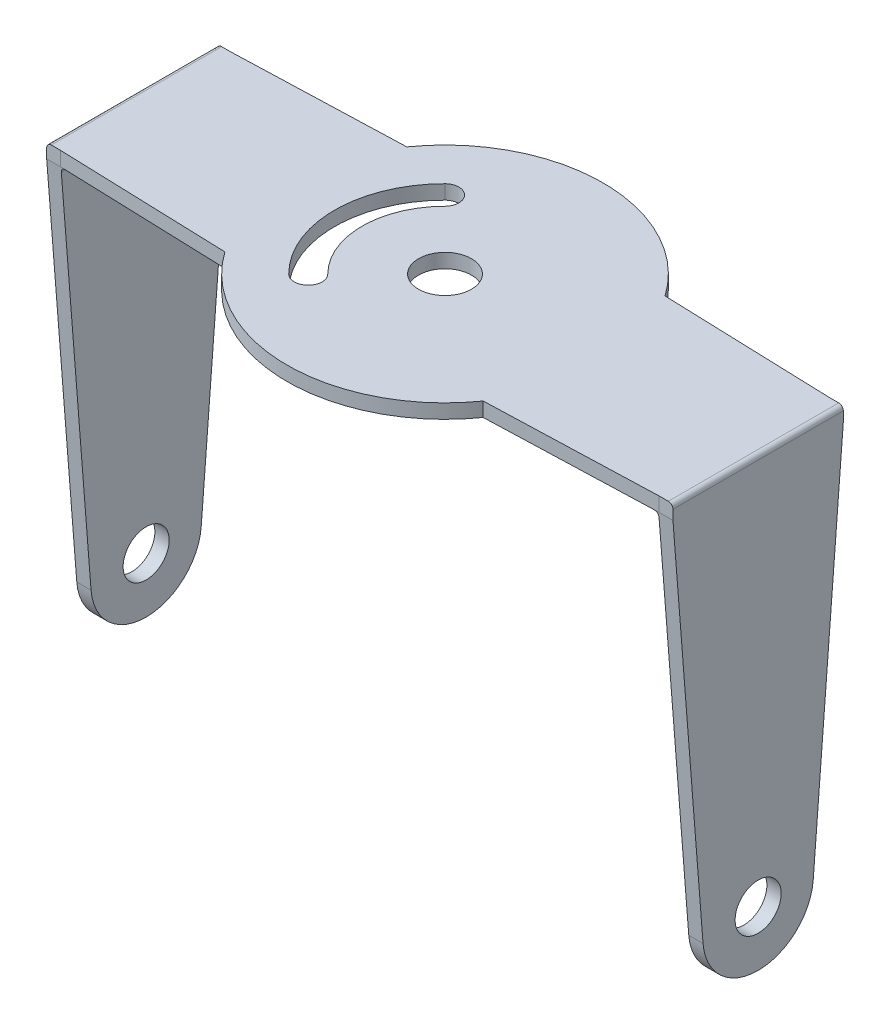
from build123d import *

# Parameters (mm, degrees)
BOSS_EXTRUDE1_DEPTH = 17.15
CUT_EXTRUDE1_DEPTH  = 69
CUT_EXTRUDE2_DEPTH  = 49.5
SKETCH4_R           = 2.875
CUT_EXTRUDE3_DEPTH  = 34.3
SKETCH5_R           = 2.5
CUT_EXTRUDE4_DEPTH  = 69
FILLET2_R           = 0.5


with BuildPart() as part:
    # Sketch1 → Boss-Extrude1 (new body, symmetric)
    with BuildSketch(Plane.XY):
        Polygon((-32.45, -6), (-32.45, 40.95), (32.45, 40.95), (32.45, -6), (34, -6), (34, 42.5), (-34, 42.5), (-34, -6), align=None)
    extrude(amount=BOSS_EXTRUDE1_DEPTH, both=True)

    # Sketch2 → Cut-Extrude1 (cut, through all)
    with BuildSketch(Plane.ZY.offset(34)):
        with BuildLine():
            Line((-5.981406604, -0.471990503), (-9.25, 40.95))
            Line((-9.25, 40.95), (-17.15, 40.95))
            Line((-17.15, 40.95), (-17.15, -6))
            Line((-17.15, -6), (0, -6))
            ThreePointArc((0, -6), (-4.07234926, -4.406355808), (-5.981406604, -0.471990503))
        make_face()
    cut_extrude1 = extrude(amount=-CUT_EXTRUDE1_DEPTH, mode=Mode.SUBTRACT)

    # Mirror1: Cut-Extrude1 across plane
    add(cut_extrude1.mirror(Plane.XY), mode=Mode.SUBTRACT)

    # Sketch3 → Cut-Extrude2 (cut, through all)
    with BuildSketch(Plane(origin=(0, 42.5, 0), x_dir=(1, 0, 0), z_dir=(0, 1, 0))):
        with BuildLine():
            Line((-32.5, -9.25), (-14.021657356, -9.875))
            ThreePointArc((-14.021657356, -9.875), (-7.898298867, -15.222988373), (0, -17.15))
            Line((0, -17.15), (-34, -17.15))
            Line((-34, -17.15), (-34, -9.25))
            Line((-34, -9.25), (-32.5, -9.25))
        make_face()
        with BuildLine():
            Line((-34, 9.25), (-34, 17.15))
            Line((-34, 17.15), (0, 17.15))
            ThreePointArc((0, 17.15), (-7.898298867, 15.222988373), (-14.021657356, 9.875))
            Line((-14.021657356, 9.875), (-32.5, 9.25))
            Line((-32.5, 9.25), (-34, 9.25))
        make_face()
    cut_extrude2 = extrude(amount=-CUT_EXTRUDE2_DEPTH, mode=Mode.SUBTRACT)

    # Mirror2: Cut-Extrude2 across plane
    add(cut_extrude2.mirror(Plane(origin=(0, 0, 0), x_dir=(0, 0, 1), z_dir=(1, 0, 0))), mode=Mode.SUBTRACT)

    # Sketch4 → Cut-Extrude3 (cut)
    with BuildSketch(Plane(origin=(0, 42.5, 0), x_dir=(1, 0, 0), z_dir=(0, 1, 0))):
        Circle(SKETCH4_R)
        with BuildLine():
            ThreePointArc((-8.485281374, 8.485281374), (-12, 0), (-8.485281374, -8.485281374))
            ThreePointArc((-8.485281374, -8.485281374), (-6.363961031, -8.485281374), (-6.363961031, -6.363961031))
            ThreePointArc((-6.363961031, -6.363961031), (-9, 0), (-6.363961031, 6.363961031))
            ThreePointArc((-6.363961031, 6.363961031), (-6.363961031, 8.485281374), (-8.485281374, 8.485281374))
        make_face()
    extrude(amount=-CUT_EXTRUDE3_DEPTH, mode=Mode.SUBTRACT)

    # Sketch5 → Cut-Extrude4 (cut, through all)
    with BuildSketch(Plane.ZY.offset(34)):
        Circle(SKETCH5_R)
    extrude(amount=-CUT_EXTRUDE4_DEPTH, mode=Mode.SUBTRACT)

    # Fillet2
    fillet2_edges = [part.edges().sort_by_distance(p)[0] for p in [
        (34, 42.5, 0),
        (32.45, 40.95, 0),
        (-32.45, 40.95, 0),
        (-34, 42.5, 0),
    ]]
    fillet(fillet2_edges, radius=FILLET2_R)


solid = part.part
